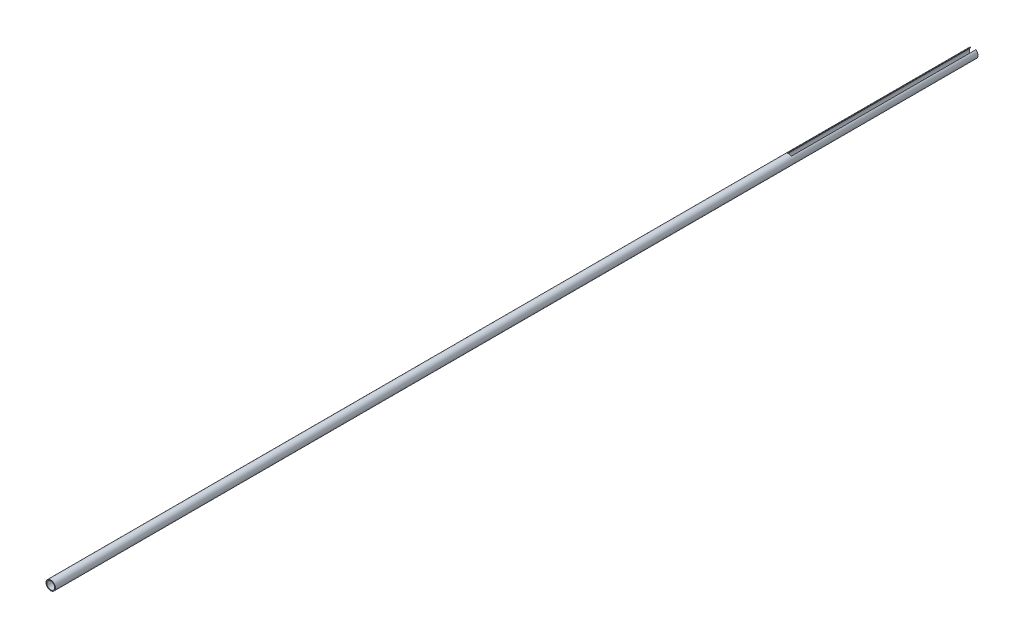
from build123d import *

# Parameters (mm, degrees)
SKETCH1_R           = 0.635
SKETCH1_R_2         = 0.5334
BOSS_EXTRUDE1_DEPTH = 125
SKETCH2_W           = 0.7
SKETCH2_H           = 0.8668
CUT_EXTRUDE1_DEPTH  = 25


with BuildPart() as part:
    # Sketch1 → Boss-Extrude1 (new body)
    with BuildSketch(Plane.XY):
        Circle(SKETCH1_R)
        Circle(SKETCH1_R_2, mode=Mode.SUBTRACT)
    extrude(amount=BOSS_EXTRUDE1_DEPTH)

    # Sketch2 → Cut-Extrude1 (cut)
    with BuildSketch(Plane.XY):
        with Locations((0, 0.5334)):
            Rectangle(SKETCH2_W, SKETCH2_H)
    extrude(amount=CUT_EXTRUDE1_DEPTH, mode=Mode.SUBTRACT)


solid = part.part
